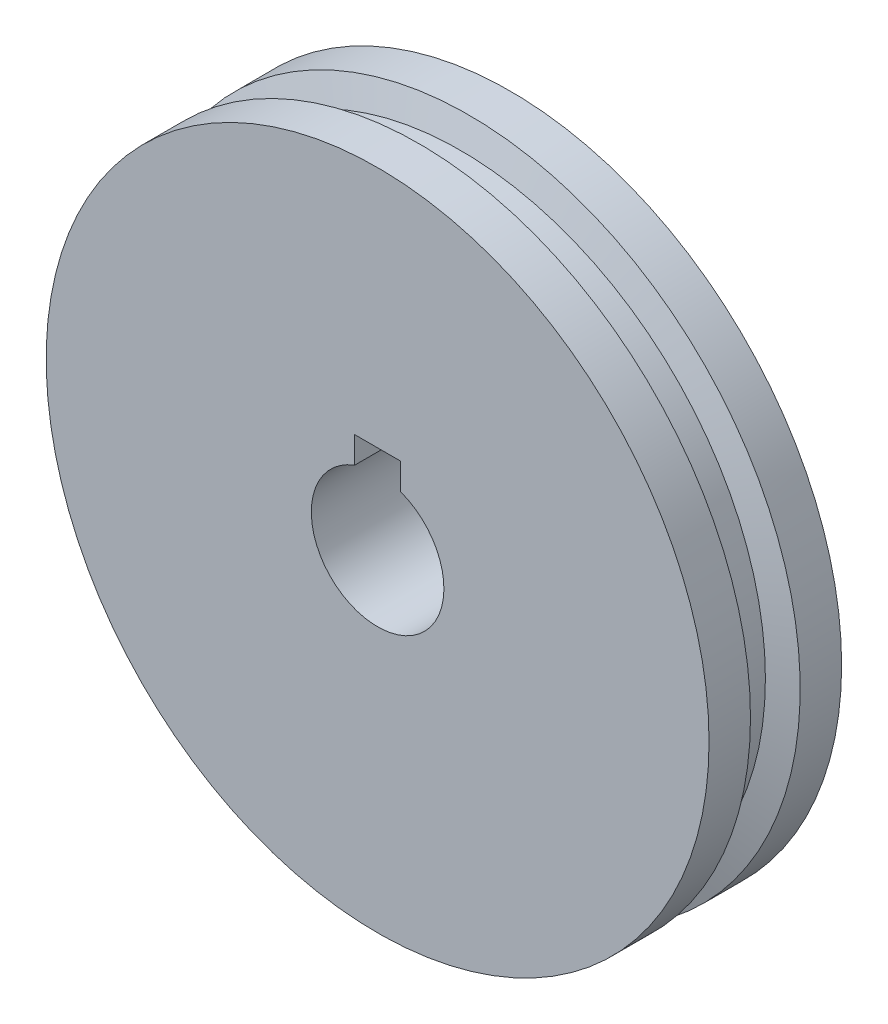
from build123d import *

# Parameters (mm, degrees)
SKETCH1_R           = 25
SKETCH1_R_2         = 5
BOSS_EXTRUDE1_DEPTH = 5
CUT_EXTRUDE1_DEPTH  = 10


with BuildPart() as part:
    # Sketch1 → Boss-Extrude1 (new body, symmetric)
    with BuildSketch(Plane.XY):
        Circle(SKETCH1_R)
        Circle(SKETCH1_R_2, mode=Mode.SUBTRACT)
    extrude(amount=BOSS_EXTRUDE1_DEPTH, both=True)

    # Sketch2 → Cut-Revolve1 (revolve, cut)
    with BuildSketch(Plane(origin=(0, 0, 0), x_dir=(0, 0, -1), z_dir=(1, 0, 0))):
        Polygon((-2.5, 27), (-1.25, 23), (1.25, 23), (2.5, 27), align=None)
    revolve(axis=Axis((0, 0, 14.237449017), (0, 0, -1)), mode=Mode.SUBTRACT)

    # Sketch3 → Cut-Extrude1 (cut)
    with BuildSketch(Plane(origin=(0, 0, -5), x_dir=(-1, 0, 0), z_dir=(0, 0, -1))):
        with BuildLine():
            Line((-1.732878986, 6.690109852), (1.732878986, 6.690109852))
            Line((1.732878986, 6.690109852), (1.732878986, 4.690109852))
            ThreePointArc((1.732878986, 4.690109852), (0, 5), (-1.732878986, 4.690109852))
            Line((-1.732878986, 4.690109852), (-1.732878986, 6.690109852))
        make_face()
    extrude(amount=-CUT_EXTRUDE1_DEPTH, mode=Mode.SUBTRACT)


solid = part.part
